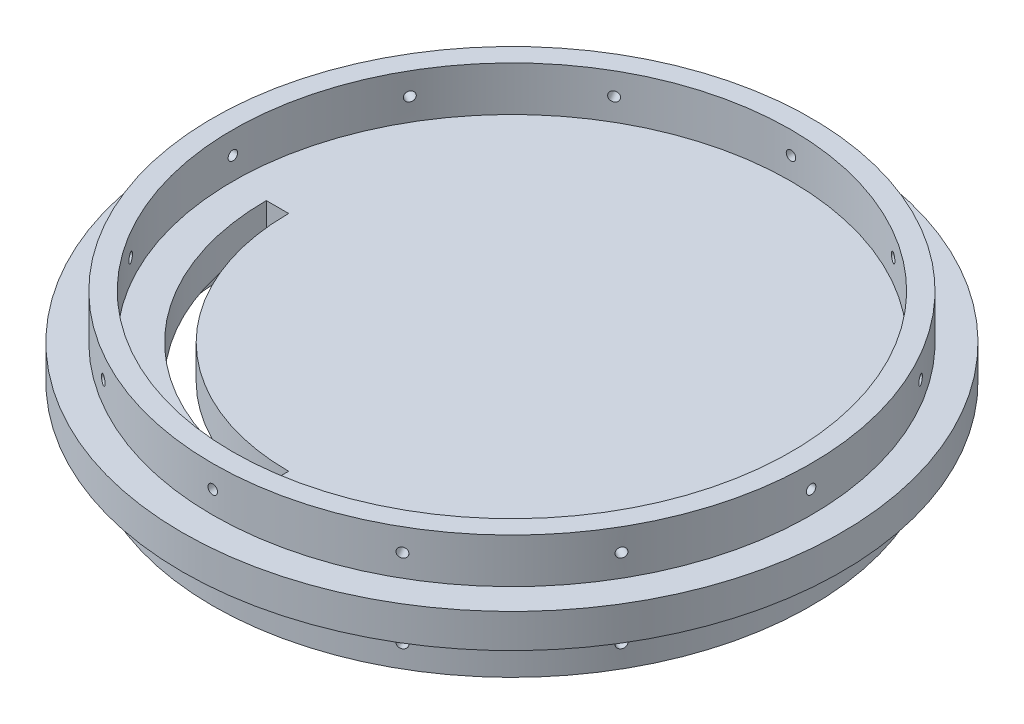
from build123d import *

# Parameters (mm, degrees)
SKETCH1_R                = 93.726
BOSS_EXTRUDE1_DEPTH      = 4.826
SKETCH4_R                = 85.09
SKETCH4_R_2              = 79.375
BOSS_EXTRUDE2_DEPTH      = 12.7
SKETCH5_R                = 1.35255
CUT_EXTRUDE2_DEPTH       = 12.7
CIRPATTERN1_COUNT        = 12
MIRROR2_COPY_1_SKETCH_R  = 1.35255
MIRROR2_COPY_1_DEPTH     = 12.7
MIRROR2_COPY_2_SKETCH_R  = 1.35255
MIRROR2_COPY_2_DEPTH     = 12.7
MIRROR2_COPY_3_SKETCH_R  = 1.35255
MIRROR2_COPY_3_DEPTH     = 12.7
MIRROR2_COPY_4_SKETCH_R  = 1.35255
MIRROR2_COPY_4_DEPTH     = 12.7
MIRROR2_COPY_5_SKETCH_R  = 1.35255
MIRROR2_COPY_5_DEPTH     = 12.7
MIRROR2_COPY_6_SKETCH_R  = 1.35255
MIRROR2_COPY_6_DEPTH     = 12.7
MIRROR2_COPY_7_SKETCH_R  = 1.35255
MIRROR2_COPY_7_DEPTH     = 12.7
MIRROR2_COPY_8_SKETCH_R  = 1.35255
MIRROR2_COPY_8_DEPTH     = 12.7
MIRROR2_COPY_9_SKETCH_R  = 1.35255
MIRROR2_COPY_9_DEPTH     = 12.7
MIRROR2_COPY_10_SKETCH_R = 1.35255
MIRROR2_COPY_10_DEPTH    = 12.7
MIRROR2_COPY_11_SKETCH_R = 1.35255
MIRROR2_COPY_11_DEPTH    = 12.7
CUT_EXTRUDE3_DEPTH       = 9.652


with BuildPart() as part:
    # Sketch1 → Boss-Extrude1 (new, symmetric)
    with BuildSketch(Plane(origin=(0, 0, 0), x_dir=(1, 0, 0), z_dir=(0, 1, 0))):
        with Locations(Location((0, 0, 0), (0, 0, 270))):
            Circle(SKETCH1_R)
    extrude(amount=BOSS_EXTRUDE1_DEPTH, both=True)

    # Sketch2 → Cut-Revolve1 (revolve, cut)
    with BuildSketch(Plane.XY, mode=Mode.PRIVATE) as cut_revolve1_sk:
        with BuildLine():
            Line((0, -4.826), (-19.2970404, -4.826))
            ThreePointArc((-19.2970404, -4.826), (-9.985310315, -2.33207385), (-0.381787908, -1.495209354))
            Line((-0.381787908, -1.495209354), (0, -1.495209354))
            Line((0, -1.495209354), (0, -4.826))
        make_face()
    revolve(cut_revolve1_sk.sketch.rotate(Axis((0, -18.327530441, 0), (0, 1, 0)), 270), axis=Axis((0, -18.327530441, 0), (0, 1, 0)), mode=Mode.SUBTRACT)

    # Sketch4 → Boss-Extrude2 (add)
    with BuildSketch(Plane(origin=(0, 4.826, 0), x_dir=(1, 0, 0), z_dir=(0, 1, 0))):
        with Locations(Location((0, 0, 0), (0, 0, 270))):
            Circle(SKETCH4_R)
        with Locations(Location((0, 0, 0), (0, 0, 270))):
            Circle(SKETCH4_R_2, mode=Mode.SUBTRACT)
    boss_extrude2 = extrude(amount=BOSS_EXTRUDE2_DEPTH)

    # Sketch5 → Cut-Extrude2 (cut)
    with BuildSketch(Plane(origin=(0, 0, -85.09), x_dir=(-1, 0, 0), z_dir=(0, 0, -1))):
        with Locations(Location((0, 11.176, 0), (0, 0, 90))):
            Circle(SKETCH5_R)
    cut_extrude2 = extrude(amount=-CUT_EXTRUDE2_DEPTH, mode=Mode.SUBTRACT)

    # CirPattern1: Cut-Extrude2 ×12 about axis
    cirpattern1_axis = Axis((0, 17.526, 0), (0, -1, 0))
    for i in range(1, CIRPATTERN1_COUNT):
        add(cut_extrude2.rotate(cirpattern1_axis, i * 360 / CIRPATTERN1_COUNT), mode=Mode.SUBTRACT)

    # Mirror2: Boss-Extrude2, Cut-Extrude2 across plane
    add(boss_extrude2.mirror(Plane.ZX))
    add(cut_extrude2.mirror(Plane.ZX), mode=Mode.SUBTRACT)

    # Mirror2 copy 1 sketch → Mirror2 copy 1 (cut)
    with BuildSketch(Plane(origin=(42.545, 0, -73.690101608), x_dir=(-0.8660254037844387, 0, -0.49999999999999994), z_dir=(0.49999999999999994, 0, -0.8660254037844387))):
        with Locations((0, -11.176)):
            Circle(MIRROR2_COPY_1_SKETCH_R)
    extrude(amount=-MIRROR2_COPY_1_DEPTH, mode=Mode.SUBTRACT)

    # Mirror2 copy 2 sketch → Mirror2 copy 2 (cut)
    with BuildSketch(Plane(origin=(73.690101608, 0, -42.545), x_dir=(-0.5000000000000001, 0, -0.8660254037844386), z_dir=(0.8660254037844386, 0, -0.5000000000000001))):
        with Locations((0, -11.176)):
            Circle(MIRROR2_COPY_2_SKETCH_R)
    extrude(amount=-MIRROR2_COPY_2_DEPTH, mode=Mode.SUBTRACT)

    # Mirror2 copy 3 sketch → Mirror2 copy 3 (cut)
    with BuildSketch(Plane(origin=(85.09, 0, 0), x_dir=(0, 0, -1), z_dir=(1, 0, 0))):
        with Locations((0, -11.176)):
            Circle(MIRROR2_COPY_3_SKETCH_R)
    extrude(amount=-MIRROR2_COPY_3_DEPTH, mode=Mode.SUBTRACT)

    # Mirror2 copy 4 sketch → Mirror2 copy 4 (cut)
    with BuildSketch(Plane(origin=(73.690101608, 0, 42.545), x_dir=(0.4999999999999998, 0, -0.8660254037844387), z_dir=(0.8660254037844387, 0, 0.4999999999999998))):
        with Locations((0, -11.176)):
            Circle(MIRROR2_COPY_4_SKETCH_R)
    extrude(amount=-MIRROR2_COPY_4_DEPTH, mode=Mode.SUBTRACT)

    # Mirror2 copy 5 sketch → Mirror2 copy 5 (cut)
    with BuildSketch(Plane(origin=(42.545, 0, 73.690101608), x_dir=(0.8660254037844387, 0, -0.49999999999999994), z_dir=(0.49999999999999994, 0, 0.8660254037844387))):
        with Locations((0, -11.176)):
            Circle(MIRROR2_COPY_5_SKETCH_R)
    extrude(amount=-MIRROR2_COPY_5_DEPTH, mode=Mode.SUBTRACT)

    # Mirror2 copy 6 sketch → Mirror2 copy 6 (cut)
    with BuildSketch(Plane.XY.offset(85.09)):
        with Locations((0, -11.176)):
            Circle(MIRROR2_COPY_6_SKETCH_R)
    extrude(amount=-MIRROR2_COPY_6_DEPTH, mode=Mode.SUBTRACT)

    # Mirror2 copy 7 sketch → Mirror2 copy 7 (cut)
    with BuildSketch(Plane(origin=(-42.545, 0, 73.690101608), x_dir=(0.8660254037844386, 0, 0.5000000000000001), z_dir=(-0.5000000000000001, 0, 0.8660254037844386))):
        with Locations((0, -11.176)):
            Circle(MIRROR2_COPY_7_SKETCH_R)
    extrude(amount=-MIRROR2_COPY_7_DEPTH, mode=Mode.SUBTRACT)

    # Mirror2 copy 8 sketch → Mirror2 copy 8 (cut)
    with BuildSketch(Plane(origin=(-73.690101608, 0, 42.545), x_dir=(0.5000000000000004, 0, 0.8660254037844384), z_dir=(-0.8660254037844384, 0, 0.5000000000000004))):
        with Locations((0, -11.176)):
            Circle(MIRROR2_COPY_8_SKETCH_R)
    extrude(amount=-MIRROR2_COPY_8_DEPTH, mode=Mode.SUBTRACT)

    # Mirror2 copy 9 sketch → Mirror2 copy 9 (cut)
    with BuildSketch(Plane.ZY.offset(85.09)):
        with Locations((0, -11.176)):
            Circle(MIRROR2_COPY_9_SKETCH_R)
    extrude(amount=-MIRROR2_COPY_9_DEPTH, mode=Mode.SUBTRACT)

    # Mirror2 copy 10 sketch → Mirror2 copy 10 (cut)
    with BuildSketch(Plane(origin=(-73.690101608, 0, -42.545), x_dir=(-0.5000000000000001, 0, 0.8660254037844386), z_dir=(-0.8660254037844386, 0, -0.5000000000000001))):
        with Locations((0, -11.176)):
            Circle(MIRROR2_COPY_10_SKETCH_R)
    extrude(amount=-MIRROR2_COPY_10_DEPTH, mode=Mode.SUBTRACT)

    # Mirror2 copy 11 sketch → Mirror2 copy 11 (cut)
    with BuildSketch(Plane(origin=(-42.545, 0, -73.690101608), x_dir=(-0.8660254037844384, 0, 0.5000000000000004), z_dir=(-0.5000000000000004, 0, -0.8660254037844384))):
        with Locations((0, -11.176)):
            Circle(MIRROR2_COPY_11_SKETCH_R)
    extrude(amount=-MIRROR2_COPY_11_DEPTH, mode=Mode.SUBTRACT)

    # Sketch6 → Cut-Extrude3 (cut)
    with BuildSketch(Plane(origin=(0, 4.826, 0), x_dir=(1, 0, 0), z_dir=(0, 1, 0))):
        with BuildLine():
            Line((-63.5, 0), (-69.85, 0))
            ThreePointArc((-69.85, 0), (-49.391408666, -49.391408666), (0, -69.85))
            Line((0, -69.85), (0, -63.5))
            ThreePointArc((0, -63.5), (-44.901280605, -44.901280605), (-63.5, 0))
        make_face()
    extrude(amount=-CUT_EXTRUDE3_DEPTH, mode=Mode.SUBTRACT)


solid = part.part
